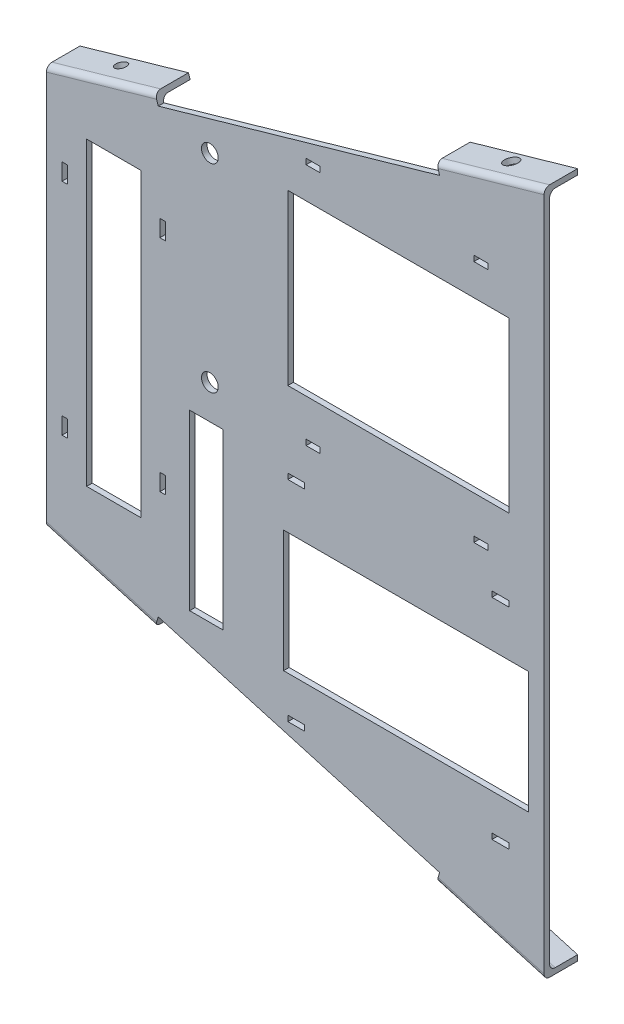
from build123d import *

# Parameters (mm, degrees)
BOSS_EXTRUDE1_DEPTH      = 2
SKETCH2_R                = 3
SKETCH2_W                = 2
SKETCH2_H                = 6
SKETCH2_W_2              = 19.404886506
SKETCH2_H_2              = 107.587058951
SKETCH2_W_3              = 12
SKETCH2_H_3              = 62.119371688
SKETCH2_W_4              = 6
SKETCH2_H_4              = 2
SKETCH2_W_5              = 5
SKETCH2_W_6              = 87.5481705
SKETCH2_H_5              = 43.571241204
SKETCH2_W_7              = 79
SKETCH2_H_6              = 60.456746524
CUT_EXTRUDE1_DEPTH       = 10
BOSS_EXTRUDE2_DEPTH      = 10
BOSS_EXTRUDE2_DEPTH_BACK = 2
FILLET1_R                = 2
CUT_EXTRUDE2_DEPTH       = 10
CUT_EXTRUDE2_DEPTH_BACK  = 10
SKETCH5_R                = 2.5
SKETCH5_R_2              = 2
CUT_EXTRUDE3_DEPTH       = 10


with BuildPart() as part:
    # Sketch1 → Boss-Extrude1 (new body)
    with BuildSketch(Plane.XY):
        Polygon((-10.904784398, -69.72039113), (-10.904784398, 69.72039113), (167.095215602, 120.741927431), (167.095215602, -120.741927431), align=None)
    extrude(amount=BOSS_EXTRUDE1_DEPTH)

    # Sketch2 → Cut-Extrude1 (cut)
    with BuildSketch(Plane.XY.offset(2)):
        with Locations((47.563666615, 2.7699494)):
            Circle(SKETCH2_R)
        with Locations((47.563666615, 73.7699494)):
            Circle(SKETCH2_R)
        with Locations((30.687477401, 41.636914827)):
            Rectangle(SKETCH2_W, SKETCH2_H)
        with Locations((30.687477401, -37.025532441)):
            Rectangle(SKETCH2_W, SKETCH2_H)
        with Locations((-4.312522599, 41.636914827)):
            Rectangle(SKETCH2_W, SKETCH2_H)
        with Locations((-4.312522599, -37.025532441)):
            Rectangle(SKETCH2_W, SKETCH2_H)
        with Locations((13.187477401, 2.305691192)):
            Rectangle(SKETCH2_W_2, SKETCH2_H_2)
        with Locations((46.32953553, -40.519587511)):
            Rectangle(SKETCH2_W_3, SKETCH2_H_3)
        with Locations((78.467345618, -87.370243237)):
            Rectangle(SKETCH2_W_4, SKETCH2_H_4)
        with Locations((78.467345618, -12.370243237)):
            Rectangle(SKETCH2_W_4, SKETCH2_H_4)
        with Locations((151.467345618, -87.370243237)):
            Rectangle(SKETCH2_W_4, SKETCH2_H_4)
        with Locations((151.467345618, -12.370243237)):
            Rectangle(SKETCH2_W_4, SKETCH2_H_4)
        with Locations((84.496263797, 1.389968406)):
            Rectangle(SKETCH2_W_5, SKETCH2_H_4)
        with Locations((84.496263797, 88.389968406)):
            Rectangle(SKETCH2_W_5, SKETCH2_H_4)
        with Locations((144.496263797, 88.389968406)):
            Rectangle(SKETCH2_W_5, SKETCH2_H_4)
        with Locations((144.496263797, 1.389968406)):
            Rectangle(SKETCH2_W_5, SKETCH2_H_4)
        with Locations((117.693260368, -51.579694355)):
            Rectangle(SKETCH2_W_6, SKETCH2_H_5)
        with Locations((114.967345618, 45.962282478)):
            Rectangle(SKETCH2_W_7, SKETCH2_H_6)
    extrude(amount=-CUT_EXTRUDE1_DEPTH, mode=Mode.SUBTRACT)

    # Sketch3 → Boss-Extrude2 (add, two sides: drawn at the far end of the back side and taken through both)
    with BuildSketch(Plane(origin=(0, 0, 0), x_dir=(-1, 0, 0), z_dir=(0, 0, -1)).offset(-BOSS_EXTRUDE2_DEPTH_BACK)):
        Polygon((10.904784398, -69.72039113), (-167.095215602, -120.741927431), (-167.095215602, -122.741927431), (10.904784398, -71.72039113), align=None)
        Polygon((-167.095215602, 120.741927431), (-167.095215602, 122.741927431), (10.904784398, 71.72039113), (10.904784398, 69.72039113), align=None)
    extrude(amount=BOSS_EXTRUDE2_DEPTH + BOSS_EXTRUDE2_DEPTH_BACK)

    # Fillet1
    fillet1_edges = [part.edges().sort_by_distance(p)[0] for p in [
        (78.095215602, 95.231159281, 0),
        (78.095215602, -95.231159281, 0),
        (78.095215602, -97.231159281, 2),
        (78.095215602, 97.231159281, 2),
    ]]
    fillet(fillet1_edges, radius=FILLET1_R)

    # Sketch4 → Cut-Extrude2 (cut, two sides: drawn at the far end of the back side and taken through both)
    with BuildSketch(Plane(origin=(0, 0, 0), x_dir=(-1, 0, 0), z_dir=(0, 0, -1)).offset(-CUT_EXTRUDE2_DEPTH_BACK)):
        Polygon((-29.095215602, 79.105365308), (-127.095215602, 107.195874059), (-129.724486678, 107.949522652), (-128.643652311, 111.720254216), (-128.09256865, 113.642832381), (-127.51525552, 115.656917896), (-124.890880959, 114.886186717), (-26.890880959, 86.105365308), align=None)
        Polygon((-127.095215602, -107.195874059), (-129.724486678, -107.949522652), (-128.643652311, -111.720254216), (-128.09256865, -113.642832381), (-127.51525552, -115.656917896), (-124.890880959, -114.886186717), (-26.890880959, -86.105365308), (-29.095215602, -79.105365308), align=None)
    extrude(amount=CUT_EXTRUDE2_DEPTH + CUT_EXTRUDE2_DEPTH_BACK, mode=Mode.SUBTRACT)

    # Sketch5 → Cut-Extrude3 (cut)
    with BuildSketch(Plane(origin=(-19.29514045, -67.315397557, 0), x_dir=(0.9612890822794596, -0.27554183038209346, 0), z_dir=(0.2755418303820934, 0.9612890822794595, 0))):
        with Locations((173.896258148, 6)):
            Circle(SKETCH5_R)
        with Locations((28.728234, 6)):
            Circle(SKETCH5_R_2)
    cut_extrude3 = extrude(amount=-CUT_EXTRUDE3_DEPTH, mode=Mode.SUBTRACT)

    # Mirror1: Cut-Extrude3 across plane
    add(cut_extrude3.mirror(Plane.ZX), mode=Mode.SUBTRACT)


solid = part.part
